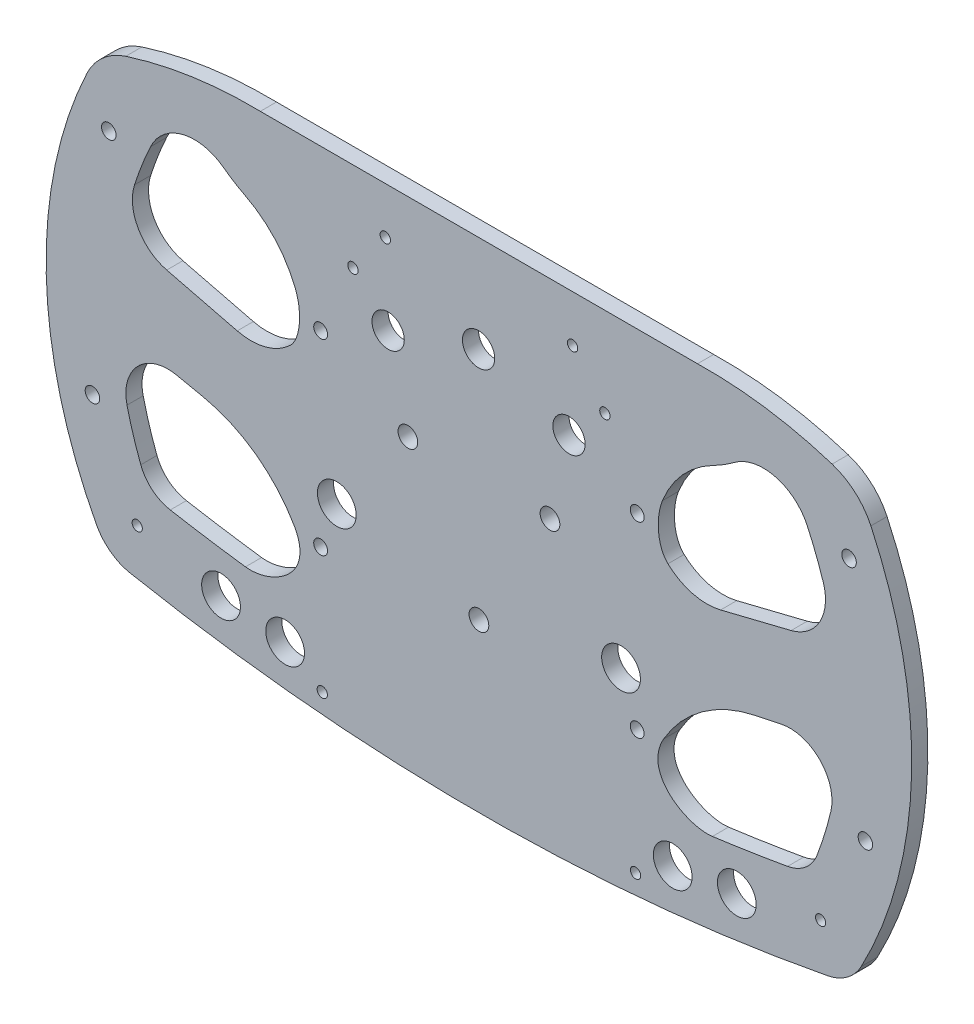
from build123d import *

# Parameters (mm, degrees)
SZKIC1_R                        = 6
SZKIC1_R_2                      = 1.6
SZKIC1_R_3                      = 2.15
DODANIE_WYCI_GNI_CIE1_DEPTH     = 5
ZAOKR_GLENIE1_R                 = 20
SFAZOWANIE1_SIZE                = 1
SZKIC2_R                        = 3.05
WYTNIJ_WYCI_GNI_CIE1_DEPTH      = 1.0000001
WYTNIJ_WYCI_GNI_CIE1_DEPTH_BACK = 6.0000001
SZKIC3_R                        = 2.25
WYTNIJ_WYCI_GNI_CIE2_DEPTH      = 1.0000001
WYTNIJ_WYCI_GNI_CIE2_DEPTH_BACK = 6.0000001
SZKIC4_R                        = 5
WYTNIJ_WYCI_GNI_CIE3_DEPTH      = 16
SZKIC5_R                        = 6
WYTNIJ_WYCI_GNI_CIE4_DEPTH      = 10
SZKIC6_R                        = 1.575
WYTNIJ_WYCI_GNI_CIE5_DEPTH      = 10
SFAZOWANIE2_SIZE                = 1


with BuildPart() as part:
    # Szkic1 → Dodanie-wyci_gni_cie1 (new body)
    with BuildSketch(Plane.XY):
        with BuildLine():
            ThreePointArc((117.467013895, 64.47868366), (93.021164267, 71.454105589), (67.678172045, 73.451308732))
            Line((67.678172045, 73.451308732), (-67.678172045, 73.451308732))
            ThreePointArc((-67.678172045, 73.451308732), (-93.021164267, 71.454105589), (-117.467013895, 64.47868366))
            ThreePointArc((-117.467013895, 64.47868366), (-133.996600631, 0.95447329), (-118.373625878, -62.798763495))
            ThreePointArc((-118.373625878, -62.798763495), (-114.037971639, -67.832241049), (-107.953613934, -70.499521549))
            ThreePointArc((-107.953613934, -70.499521549), (0, -80.778253493), (107.953613934, -70.499521549))
            ThreePointArc((107.953613934, -70.499521549), (114.037971639, -67.832241049), (118.373625878, -62.798763495))
            ThreePointArc((118.373625878, -62.798763495), (133.996600631, 0.95447329), (117.467013895, 64.47868366))
        make_face()
        with Locations((-79.843156229, -62.51471301)):
            Circle(SZKIC1_R, mode=Mode.SUBTRACT)
        with Locations((-60, -65.014543178)):
            Circle(SZKIC1_R, mode=Mode.SUBTRACT)
        with BuildLine():
            Line((-93.639920436, -10.215979742), (-85.426816489, -11.936656557))
            ThreePointArc((-85.426816489, -11.936656557), (-69.154538898, -19.133220925), (-57.227836692, -32.336679986))
            add(Edge.make_bspline(
                [(-72.285057891, -50.981377576), (-64.366611345, -52.03697099), (-50.388689008, -44.15086566), (-57.227836692, -32.336679986)],
                knots=[0, 0, 0, 0, 1, 1, 1, 1], degree=3))
            ThreePointArc((-72.285057891, -50.981377576), (-83.943779984, -49.299228552), (-95.563579221, -47.366434753))
            ThreePointArc((-95.563579221, -47.366434753), (-101.119264644, -44.79470717), (-104.683334782, -39.817074466))
            ThreePointArc((-104.683334782, -39.817074466), (-107.042286981, -32.953737236), (-108.951787413, -25.952033051))
            ThreePointArc((-108.951787413, -25.952033051), (-105.622705702, -13.873790687), (-93.639920436, -10.215979742))
        make_face(mode=Mode.SUBTRACT)
        with Locations((60, -65.014543178)):
            Circle(SZKIC1_R, mode=Mode.SUBTRACT)
        with Locations((79.843156229, -62.51471301)):
            Circle(SZKIC1_R, mode=Mode.SUBTRACT)
        with BuildLine():
            ThreePointArc((57.227836692, -32.336679986), (69.154538898, -19.133220925), (85.426816489, -11.936656557))
            Line((85.426816489, -11.936656557), (93.639920436, -10.215979742))
            ThreePointArc((93.639920436, -10.215979742), (105.622705702, -13.873790687), (108.951787413, -25.952033051))
            ThreePointArc((108.951787413, -25.952033051), (107.042286981, -32.953737236), (104.683334782, -39.817074466))
            ThreePointArc((104.683334782, -39.817074466), (101.119264644, -44.79470717), (95.563579221, -47.366434753))
            ThreePointArc((95.563579221, -47.366434753), (83.943779984, -49.299228552), (72.285057891, -50.981377576))
            add(Edge.make_bspline(
                [(72.285057891, -50.981377576), (64.366611345, -52.03697099), (50.388689008, -44.15086566), (57.227836692, -32.336679986)],
                knots=[0, 0, 0, 0, 1, 1, 1, 1], degree=3))
        make_face(mode=Mode.SUBTRACT)
        with BuildLine():
            Line((-74.826032056, 11.014530402), (-96.655711946, 16.415211274))
            ThreePointArc((-96.655711946, 16.415211274), (-105.521825108, 23.188783802), (-106.621107385, 34.291973698))
            ThreePointArc((-106.621107385, 34.291973698), (-104.340687454, 40.706522101), (-101.674756414, 46.970670723))
            ThreePointArc((-101.674756414, 46.970670723), (-91.74794023, 55.218917354), (-79.089039168, 52.703469899))
            ThreePointArc((-79.089039168, 52.703469899), (-75.870232147, 50.506568408), (-72.478506287, 48.587378348))
            ThreePointArc((-72.478506287, 48.587378348), (-63.066485572, 41.379596603), (-56.80899086, 31.310733134))
            add(Edge.make_bspline(
                [(-58.521368144, 15.244283258), (-55.163116948, 18.373947188), (-54.683502949, 25.918210288), (-56.80899086, 31.310733134)],
                knots=[0, 0, 0, 0, 1, 1, 1, 1], degree=3))
            ThreePointArc((-58.521368144, 15.244283258), (-66.137786774, 11.063591883), (-74.826032056, 11.014530402))
        make_face(mode=Mode.SUBTRACT)
        with BuildLine():
            Line((96.655711946, 16.415211274), (74.826032056, 11.014530402))
            ThreePointArc((74.826032056, 11.014530402), (66.137786774, 11.063591883), (58.521368144, 15.244283258))
            add(Edge.make_bspline(
                [(58.521368144, 15.244283258), (55.163116948, 18.373947188), (54.683502949, 25.918210288), (56.80899086, 31.310733134)],
                knots=[0, 0, 0, 0, 1, 1, 1, 1], degree=3))
            ThreePointArc((56.80899086, 31.310733134), (63.066485572, 41.379596603), (72.478506287, 48.587378348))
            ThreePointArc((72.478506287, 48.587378348), (75.870232147, 50.506568408), (79.089039168, 52.703469899))
            ThreePointArc((79.089039168, 52.703469899), (91.74794023, 55.218917354), (101.674756414, 46.970670723))
            ThreePointArc((101.674756414, 46.970670723), (104.340687454, 40.706522101), (106.621107385, 34.291973698))
            ThreePointArc((106.621107385, 34.291973698), (105.521825108, 23.188783802), (96.655711946, 16.415211274))
        make_face(mode=Mode.SUBTRACT)
        with Locations((-29, 59)):
            Circle(SZKIC1_R_2, mode=Mode.SUBTRACT)
        with Locations((29, 59)):
            Circle(SZKIC1_R_2, mode=Mode.SUBTRACT)
        with Locations((39, 45.817716041)):
            Circle(SZKIC1_R_2, mode=Mode.SUBTRACT)
        with Locations((-39, 45.817716041)):
            Circle(SZKIC1_R_2, mode=Mode.SUBTRACT)
        with Locations((-49, 24)):
            Circle(SZKIC1_R_3, mode=Mode.SUBTRACT)
        with Locations((49, 24)):
            Circle(SZKIC1_R_3, mode=Mode.SUBTRACT)
        with Locations((-49, -34)):
            Circle(SZKIC1_R_3, mode=Mode.SUBTRACT)
        with Locations((49, -34)):
            Circle(SZKIC1_R_3, mode=Mode.SUBTRACT)
        with Locations((48.501518409, -72.659085912)):
            Circle(SZKIC1_R_2, mode=Mode.SUBTRACT)
        with Locations((-48.501518409, -72.659085912)):
            Circle(SZKIC1_R_2, mode=Mode.SUBTRACT)
    extrude(amount=DODANIE_WYCI_GNI_CIE1_DEPTH)

    # Zaokr_glenie1
    zaokr_glenie1_edges = [part.edges().sort_by_distance(p)[0] for p in [
        (117.467013895, 64.47868366, 2.5),
        (-117.467013895, 64.47868366, 2.5),
    ]]
    fillet(zaokr_glenie1_edges, radius=ZAOKR_GLENIE1_R)

    # Sfazowanie1
    sfazowanie1_edges = [part.edges().sort_by_distance(p)[0] for p in [
        (-50.101518409, -72.659085912, 0),
        (46.901518409, -72.659085912, 0),
        (46.85, -34, 0),
        (37.4, 45.817716041, 0),
        (-40.6, 45.817716041, 0),
        (-51.15, 24, 0),
        (46.85, 24, 0),
        (-51.15, -34, 0),
        (-30.6, 59, 0),
        (27.4, 59, 0),
    ]]
    chamfer(sfazowanie1_edges, length=SFAZOWANIE1_SIZE)

    # Szkic2 → Wytnij-wyci_gni_cie1 (cut, two sides)
    with BuildSketch(Plane.XY.offset(5)) as wytnij_wyci_gni_cie1_sk:
        with Locations((0.003475223, -29.063691268)):
            Circle(SZKIC2_R)
        with Locations((22.00052048, 9.036308732)):
            Circle(SZKIC2_R)
        with Locations((-21.993570033, 9.036308732)):
            Circle(SZKIC2_R)
    extrude(amount=WYTNIJ_WYCI_GNI_CIE1_DEPTH, mode=Mode.SUBTRACT)
    extrude(wytnij_wyci_gni_cie1_sk.sketch, amount=-WYTNIJ_WYCI_GNI_CIE1_DEPTH_BACK, mode=Mode.SUBTRACT)

    # Szkic3 → Wytnij-wyci_gni_cie2 (cut, two sides)
    with BuildSketch(Plane(origin=(0, 0, 0), x_dir=(-1, 0, 0), z_dir=(0, 0, -1))) as wytnij_wyci_gni_cie2_sk:
        with Locations((114.588433544, 44.704484093)):
            Circle(SZKIC3_R)
        with Locations((119.652409391, -28.500893439)):
            Circle(SZKIC3_R)
        with Locations((-119.652409391, -28.500893439)):
            Circle(SZKIC3_R)
        with Locations((-114.588433544, 44.704484093)):
            Circle(SZKIC3_R)
    extrude(amount=WYTNIJ_WYCI_GNI_CIE2_DEPTH, mode=Mode.SUBTRACT)
    extrude(wytnij_wyci_gni_cie2_sk.sketch, amount=-WYTNIJ_WYCI_GNI_CIE2_DEPTH_BACK, mode=Mode.SUBTRACT)

    # Szkic4 → Wytnij-wyci_gni_cie3 (cut)
    with BuildSketch(Plane(origin=(0, 0, 0), x_dir=(-1, 0, 0), z_dir=(0, 0, -1))):
        with Locations((0.11301634, 43.451308732)):
            Circle(SZKIC4_R)
        with Locations((-27.88698366, 34.451308732)):
            Circle(SZKIC4_R)
        with Locations((28.11301634, 34.451308732)):
            Circle(SZKIC4_R)
    extrude(amount=-WYTNIJ_WYCI_GNI_CIE3_DEPTH, mode=Mode.SUBTRACT)

    # Szkic5 → Wytnij-wyci_gni_cie4 (cut)
    with BuildSketch(Plane(origin=(0, 0, 0), x_dir=(-1, 0, 0), z_dir=(0, 0, -1))):
        with Locations((44, -20)):
            Circle(SZKIC5_R)
        with Locations((-44, -20)):
            Circle(SZKIC5_R)
    extrude(amount=-WYTNIJ_WYCI_GNI_CIE4_DEPTH, mode=Mode.SUBTRACT)

    # Szkic6 → Wytnij-wyci_gni_cie5 (cut)
    with BuildSketch(Plane(origin=(0, 0, 0), x_dir=(-1, 0, 0), z_dir=(0, 0, -1))):
        with Locations((105.78946688, -56.662469542)):
            Circle(SZKIC6_R)
        with Locations((-105.78946688, -56.662469542)):
            Circle(SZKIC6_R)
    extrude(amount=-WYTNIJ_WYCI_GNI_CIE5_DEPTH, mode=Mode.SUBTRACT)

    # Sfazowanie2
    sfazowanie2_edges = [part.edges().sort_by_distance(p)[0] for p in [
        (-104.21446688, -56.662469542, 0),
        (107.36446688, -56.662469542, 0),
    ]]
    chamfer(sfazowanie2_edges, length=SFAZOWANIE2_SIZE)


solid = part.part
